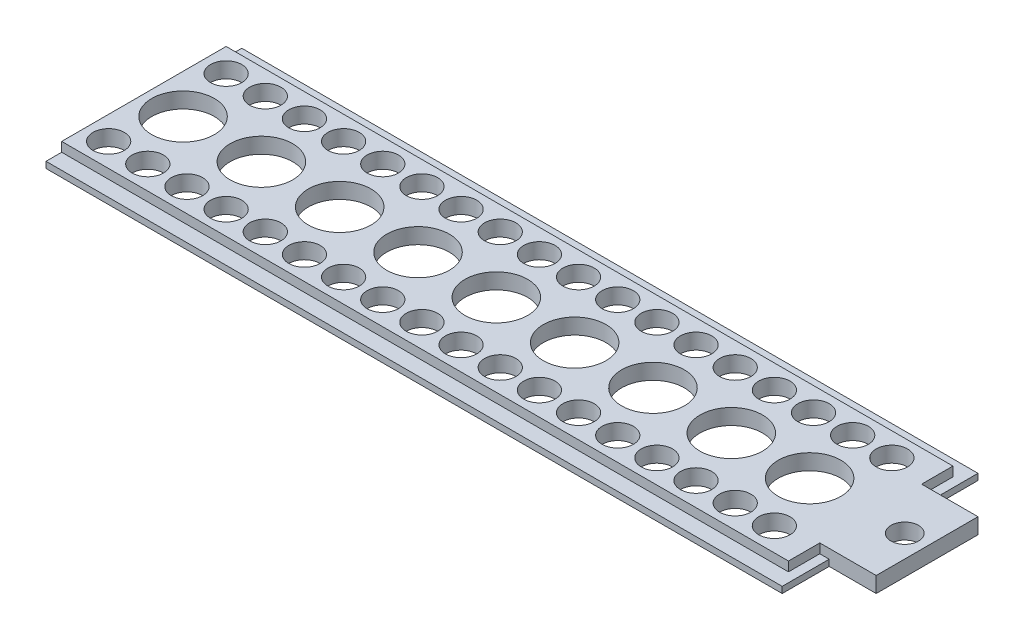
from build123d import *

# Parameters (mm, degrees)
SKIZZE1_W                       = 25
SKIZZE1_H                       = 2
AUFSATZ_LINEAR_AUSTRAGEN1_DEPTH = 100
SKIZZE2_W                       = 2
SKIZZE2_H                       = 1.2
SCHNITT_LINEAR_AUSTRAGEN1_DEPTH = 101
SKIZZE3_R                       = 1.75
SKIZZE3_W                       = 6
SKIZZE3_H                       = 6
SCHNITT_LINEAR_AUSTRAGEN2_DEPTH = 3
SKIZZE4_W                       = 4
SKIZZE4_H                       = 1.2
SCHNITT_LINEAR_AUSTRAGEN3_DEPTH = 1.2
SKIZZE5_R                       = 2
SKIZZE5_R_2                     = 4
SCHNITT_LINEAR_AUSTRAGEN4_DEPTH = 3
LINEARES_MUSTER1_COUNT          = 9
LINEARES_MUSTER1_PITCH          = 10


with BuildPart() as part:
    # Skizze1 → Aufsatz-Linear austragen1 (new body)
    with BuildSketch(Plane(origin=(0, 0, 0), x_dir=(0, 0, -1), z_dir=(1, 0, 0))):
        with Locations((-28.15591013, -26.369664989)):
            Rectangle(SKIZZE1_W, SKIZZE1_H)
    extrude(amount=AUFSATZ_LINEAR_AUSTRAGEN1_DEPTH)

    # Skizze2 → Schnitt-Linear austragen1 (cut, through all)
    with BuildSketch(Plane.ZY):
        with Locations((16.65591013, -25.969664989)):
            Rectangle(SKIZZE2_W, SKIZZE2_H)
        with Locations((39.65591013, -25.969664989)):
            Rectangle(SKIZZE2_W, SKIZZE2_H)
    extrude(amount=-SCHNITT_LINEAR_AUSTRAGEN1_DEPTH, mode=Mode.SUBTRACT)

    # Skizze3 → Schnitt-Linear austragen2 (cut, through all)
    with BuildSketch(Plane(origin=(0, -25.369664989, 0), x_dir=(1, 0, 0), z_dir=(0, 1, 0))):
        with Locations((97.15, -28.15591013)):
            Circle(SKIZZE3_R)
        with Locations((97, -18.65591013)):
            Rectangle(SKIZZE3_W, SKIZZE3_H)
        with Locations((97, -37.65591013)):
            Rectangle(SKIZZE3_W, SKIZZE3_H)
    extrude(amount=-SCHNITT_LINEAR_AUSTRAGEN2_DEPTH, mode=Mode.SUBTRACT)

    # Skizze4 → Schnitt-Linear austragen3 (cut)
    with BuildSketch(Plane(origin=(94, 0, 0), x_dir=(0, 0, -1), z_dir=(1, 0, 0))):
        with Locations((-36.65591013, -25.969664989)):
            Rectangle(SKIZZE4_W, SKIZZE4_H)
        with Locations((-19.65591013, -25.969664989)):
            Rectangle(SKIZZE4_W, SKIZZE4_H)
    extrude(amount=-SCHNITT_LINEAR_AUSTRAGEN3_DEPTH, mode=Mode.SUBTRACT)

    # Skizze5 → Schnitt-Linear austragen4 (cut, through all)
    with BuildSketch(Plane(origin=(0, -25.369664989, 0), x_dir=(1, 0, 0), z_dir=(0, 1, 0))):
        with Locations((3, -20.65591013)):
            Circle(SKIZZE5_R)
        with Locations((5, -28.15591013)):
            Circle(SKIZZE5_R_2)
        with Locations((3, -35.65591013)):
            Circle(SKIZZE5_R)
        with Locations((8, -35.65591013)):
            Circle(SKIZZE5_R)
        with Locations((8, -20.65591013)):
            Circle(SKIZZE5_R)
    schnitt_linear_austragen4 = extrude(amount=-SCHNITT_LINEAR_AUSTRAGEN4_DEPTH, mode=Mode.SUBTRACT)

    # Lineares Muster1: Schnitt-Linear austragen4 ×9
    with Locations(*[(i * LINEARES_MUSTER1_PITCH, 0, 0) for i in range(1, LINEARES_MUSTER1_COUNT)]):
        add(schnitt_linear_austragen4, mode=Mode.SUBTRACT)


solid = part.part
